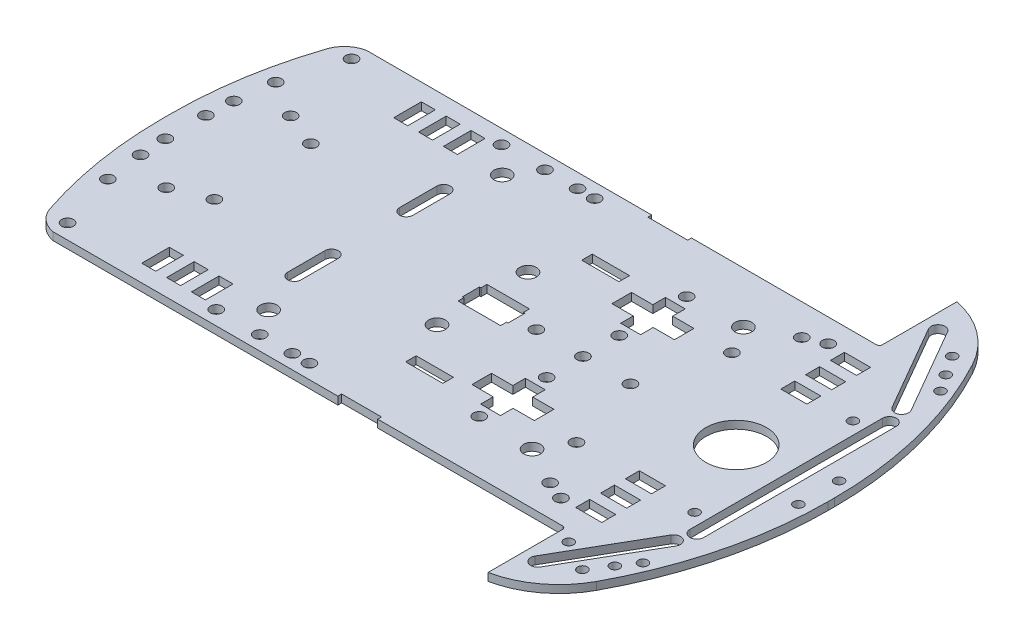
from build123d import *

# Parameters (mm, degrees)
BOSS_EXTRUDE1_DEPTH = 2.5
FILLET1_R           = 1
SKETCH2_W           = 12.85
SKETCH2_H           = 1.22
CUT_EXTRUDE1_DEPTH  = 2.5
SKETCH3_W           = 4.5
SKETCH3_H           = 8.9
CUT_EXTRUDE2_DEPTH  = 2.5
CUT_EXTRUDE3_DEPTH  = 2.5
SKETCH5_R           = 1.9
CUT_EXTRUDE4_DEPTH  = 2.5
SKETCH6_W           = 12
SKETCH6_H           = 3.4
CUT_EXTRUDE5_DEPTH  = 2.5
SKETCH7_W           = 8.4
SKETCH7_H           = 4.5
CUT_EXTRUDE6_DEPTH  = 2.5
SKETCH8_R           = 9.75
CUT_EXTRUDE7_DEPTH  = 2.5
SKETCH9_R           = 2.7
CUT_EXTRUDE8_DEPTH  = 2.5
SKETCH10_R          = 1.9
CUT_EXTRUDE9_DEPTH  = 2.5
SKETCH11_R          = 1.9
CUT_EXTRUDE10_DEPTH = 2.5
SKETCH12_R          = 1.9
CUT_EXTRUDE11_DEPTH = 2.5
SKETCH13_R          = 1.55
CUT_EXTRUDE12_DEPTH = 2.5
SKETCH14_R          = 1.55
CUT_EXTRUDE13_DEPTH = 2.5
SKETCH15_R          = 2.7
CUT_EXTRUDE14_DEPTH = 2.5
SKETCH16_R          = 1.9
CUT_EXTRUDE15_DEPTH = 2.5
SKETCH17_R          = 1.9
CUT_EXTRUDE16_DEPTH = 2.5
CUT_EXTRUDE17_DEPTH = 2.5
CUT_EXTRUDE18_DEPTH = 2.5
CUT_EXTRUDE19_DEPTH = 2.5
SKETCH21_R          = 1.55
CUT_EXTRUDE20_DEPTH = 2.5


with BuildPart() as part:
    # Sketch1 → Boss-Extrude1 (new body)
    with BuildSketch(Plane(origin=(0, 0, 0), x_dir=(1, 0, 0), z_dir=(0, 1, 0))):
        with BuildLine():
            Line((165, 101.05), (165, 126.05))
            ThreePointArc((165, 126.05), (176.651902275, 120.752536367), (185, 111.05))
            ThreePointArc((185, 111.05), (196.19228575, 82.2179374), (200, 51.525))
            Line((200, 51.525), (200, 49.525))
            ThreePointArc((200, 49.525), (196.19228575, 18.8320626), (185, -10))
            ThreePointArc((185, -10), (176.651902275, -19.702536367), (165, -25))
            Line((165, -25), (165, 0))
            Line((165, 0), (0, 0))
            ThreePointArc((0, 0), (-4.329635162, 2.032092311), (-7, 6))
            ThreePointArc((-7, 6), (-12.238570145, 27.229641406), (-14, 49.025))
            Line((-14, 49.025), (-14, 52.025))
            ThreePointArc((-14, 52.025), (-12.238570145, 73.820358594), (-7, 95.05))
            ThreePointArc((-7, 95.05), (-4.329635162, 99.017907689), (0, 101.05))
            Line((0, 101.05), (165, 101.05))
        make_face()
    extrude(amount=BOSS_EXTRUDE1_DEPTH)

    # Fillet1
    fillet1_edges = [part.edges().sort_by_distance(p)[0] for p in [
        (165, 1.25, -101.05),
        (165, 1.25, 0),
    ]]
    fillet(fillet1_edges, radius=FILLET1_R)

    # Sketch2 → Cut-Extrude1 (cut)
    with BuildSketch(Plane(origin=(0, 2.5, 0), x_dir=(1, 0, 0), z_dir=(0, 1, 0))):
        with Locations((98.075, 100.44)):
            Rectangle(SKETCH2_W, SKETCH2_H)
        with Locations((98.075, 0.61)):
            Rectangle(SKETCH2_W, SKETCH2_H)
    extrude(amount=-CUT_EXTRUDE1_DEPTH, mode=Mode.SUBTRACT)

    # Sketch3 → Cut-Extrude2 (cut)
    with BuildSketch(Plane(origin=(0, 2.5, 0), x_dir=(1, 0, 0), z_dir=(0, 1, 0))):
        with Locations((25.25, 91.1)):
            Rectangle(SKETCH3_W, SKETCH3_H)
        with Locations((33.25, 91.1)):
            Rectangle(SKETCH3_W, SKETCH3_H)
        with Locations((41.25, 91.1)):
            Rectangle(SKETCH3_W, SKETCH3_H)
        with Locations((41.25, 9.95)):
            Rectangle(SKETCH3_W, SKETCH3_H)
        with Locations((33.25, 9.95)):
            Rectangle(SKETCH3_W, SKETCH3_H)
        with Locations((25.25, 9.95)):
            Rectangle(SKETCH3_W, SKETCH3_H)
    extrude(amount=-CUT_EXTRUDE2_DEPTH, mode=Mode.SUBTRACT)

    # Sketch4 → Cut-Extrude3 (cut)
    with BuildSketch(Plane(origin=(0, 2.5, 0), x_dir=(1, 0, 0), z_dir=(0, 1, 0))):
        Polygon((84.48, 55.175), (84.48, 53.245), (84, 53.245), (84, 47.805), (84.48, 47.805), (84.48, 45.875), (98.18, 45.875), (98.18, 47.805), (98.66, 47.805), (98.66, 53.245), (98.18, 53.245), (98.18, 55.175), align=None)
    extrude(amount=-CUT_EXTRUDE3_DEPTH, mode=Mode.SUBTRACT)

    # Sketch5 → Cut-Extrude4 (cut)
    with BuildSketch(Plane(origin=(0, 2.5, 0), x_dir=(1, 0, 0), z_dir=(0, 1, 0))):
        with Locations((105.06, 50.525)):
            Circle(SKETCH5_R)
        with Locations((120.06, 50.525)):
            Circle(SKETCH5_R)
        with Locations((135.36, 50.525)):
            Circle(SKETCH5_R)
        with Locations((120.06, 62.225)):
            Circle(SKETCH5_R)
        with Locations((120.06, 83.925)):
            Circle(SKETCH5_R)
        with Locations((120.06, 17.125)):
            Circle(SKETCH5_R)
        with Locations((120.06, 38.825)):
            Circle(SKETCH5_R)
        Polygon((116.86, 65.875), (120.06, 65.875), (123.26, 65.875), (123.26, 69.925), (130.11, 69.925), (130.11, 76.225), (123.26, 76.225), (123.26, 80.275), (116.86, 80.275), (116.86, 76.225), (110.01, 76.225), (110.01, 69.925), (116.86, 69.925), align=None)
        Polygon((116.86, 31.125), (116.86, 35.175), (120.06, 35.175), (123.26, 35.175), (123.26, 31.125), (130.11, 31.125), (130.11, 24.825), (123.26, 24.825), (123.26, 20.775), (116.86, 20.775), (116.86, 24.825), (110.01, 24.825), (110.01, 31.125), align=None)
    extrude(amount=-CUT_EXTRUDE4_DEPTH, mode=Mode.SUBTRACT)

    # Sketch6 → Cut-Extrude5 (cut)
    with BuildSketch(Plane(origin=(0, 2.5, 0), x_dir=(1, 0, 0), z_dir=(0, 1, 0))):
        with Locations((99, 78.88)):
            Rectangle(SKETCH6_W, SKETCH6_H)
        with Locations((99, 22.17)):
            Rectangle(SKETCH6_W, SKETCH6_H)
    extrude(amount=-CUT_EXTRUDE5_DEPTH, mode=Mode.SUBTRACT)

    # Sketch7 → Cut-Extrude6 (cut)
    with BuildSketch(Plane(origin=(0, 2.5, 0), x_dir=(1, 0, 0), z_dir=(0, 1, 0))):
        with Locations((165.2, 91.55)):
            Rectangle(SKETCH7_W, SKETCH7_H)
        with Locations((165.2, 83.55)):
            Rectangle(SKETCH7_W, SKETCH7_H)
        with Locations((165.2, 75.55)):
            Rectangle(SKETCH7_W, SKETCH7_H)
        with Locations((165.2, 25.5)):
            Rectangle(SKETCH7_W, SKETCH7_H)
        with Locations((165.2, 17.5)):
            Rectangle(SKETCH7_W, SKETCH7_H)
        with Locations((165.2, 9.5)):
            Rectangle(SKETCH7_W, SKETCH7_H)
    extrude(amount=-CUT_EXTRUDE6_DEPTH, mode=Mode.SUBTRACT)

    # Sketch8 → Cut-Extrude7 (cut)
    with BuildSketch(Plane(origin=(0, 2.5, 0), x_dir=(1, 0, 0), z_dir=(0, 1, 0))):
        with Locations((169.41, 50.525)):
            Circle(SKETCH8_R)
    extrude(amount=-CUT_EXTRUDE7_DEPTH, mode=Mode.SUBTRACT)

    # Sketch9 → Cut-Extrude8 (cut)
    with BuildSketch(Plane(origin=(0, 2.5, 0), x_dir=(1, 0, 0), z_dir=(0, 1, 0))):
        with Locations((87.7, 65.175)):
            Circle(SKETCH9_R)
        with Locations((87.7, 35.875)):
            Circle(SKETCH9_R)
        with Locations((56.45, 88.15)):
            Circle(SKETCH9_R)
        with Locations((56.45, 12.9)):
            Circle(SKETCH9_R)
    extrude(amount=-CUT_EXTRUDE8_DEPTH, mode=Mode.SUBTRACT)

    # Sketch10 → Cut-Extrude9 (cut)
    with BuildSketch(Plane(origin=(0, 2.5, 0), x_dir=(1, 0, 0), z_dir=(0, 1, 0))):
        with Locations((47.9, 96.45)):
            Circle(SKETCH10_R)
        with Locations((61.9, 96.45)):
            Circle(SKETCH10_R)
        with Locations((72.4, 96.45)):
            Circle(SKETCH10_R)
        with Locations((77.9, 96.45)):
            Circle(SKETCH10_R)
        with Locations((77.9, 4.6)):
            Circle(SKETCH10_R)
        with Locations((72.4, 4.6)):
            Circle(SKETCH10_R)
        with Locations((61.9, 4.6)):
            Circle(SKETCH10_R)
        with Locations((47.9, 4.6)):
            Circle(SKETCH10_R)
    extrude(amount=-CUT_EXTRUDE9_DEPTH, mode=Mode.SUBTRACT)

    # Sketch11 → Cut-Extrude10 (cut)
    with BuildSketch(Plane(origin=(0, 2.5, 0), x_dir=(1, 0, 0), z_dir=(0, 1, 0))):
        with Locations((-0.2, 96.25)):
            Circle(SKETCH11_R)
        with Locations((-0.2, 4.8)):
            Circle(SKETCH11_R)
        with Locations((-5.9, 77.55)):
            Circle(SKETCH11_R)
        with Locations((-7.4, 65.55)):
            Circle(SKETCH11_R)
        with Locations((-7.9, 57.05)):
            Circle(SKETCH11_R)
        with Locations((-7.9, 44)):
            Circle(SKETCH11_R)
        with Locations((-7.4, 35.5)):
            Circle(SKETCH11_R)
        with Locations((-5.9, 23.5)):
            Circle(SKETCH11_R)
    extrude(amount=-CUT_EXTRUDE10_DEPTH, mode=Mode.SUBTRACT)

    # Sketch12 → Cut-Extrude11 (cut)
    with BuildSketch(Plane(origin=(0, 2.5, 0), x_dir=(1, 0, 0), z_dir=(0, 1, 0))):
        with Locations((5.9, 70.55)):
            Circle(SKETCH12_R)
        with Locations((16.9, 66.05)):
            Circle(SKETCH12_R)
        with Locations((5.9, 30.5)):
            Circle(SKETCH12_R)
        with Locations((16.9, 35)):
            Circle(SKETCH12_R)
    extrude(amount=-CUT_EXTRUDE11_DEPTH, mode=Mode.SUBTRACT)

    # Sketch13 → Cut-Extrude12 (cut)
    with BuildSketch(Plane(origin=(0, 2.5, 0), x_dir=(1, 0, 0), z_dir=(0, 1, 0))):
        with Locations((196, 57.075)):
            Circle(SKETCH13_R)
        with Locations((196, 43.975)):
            Circle(SKETCH13_R)
        with Locations((181.5, 25.025)):
            Circle(SKETCH13_R)
        with Locations((181.5, 76.025)):
            Circle(SKETCH13_R)
    extrude(amount=-CUT_EXTRUDE12_DEPTH, mode=Mode.SUBTRACT)

    # Sketch14 → Cut-Extrude13 (cut)
    with BuildSketch(Plane(origin=(0, 2.5, 0), x_dir=(1, 0, 0), z_dir=(0, 1, 0))):
        with Locations((169.5, -3.5)):
            Circle(SKETCH14_R)
    extrude(amount=-CUT_EXTRUDE13_DEPTH, mode=Mode.SUBTRACT)

    # Sketch15 → Cut-Extrude14 (cut)
    with BuildSketch(Plane(origin=(0, 2.5, 0), x_dir=(1, 0, 0), z_dir=(0, 1, 0))):
        with Locations((137.7, 16.5)):
            Circle(SKETCH15_R)
        with Locations((137.7, 84.55)):
            Circle(SKETCH15_R)
    extrude(amount=-CUT_EXTRUDE14_DEPTH, mode=Mode.SUBTRACT)

    # Sketch16 → Cut-Extrude15 (cut)
    with BuildSketch(Plane(origin=(0, 2.5, 0), x_dir=(1, 0, 0), z_dir=(0, 1, 0))):
        with Locations((143, 25.5)):
            Circle(SKETCH16_R)
        with Locations((143, 75.55)):
            Circle(SKETCH16_R)
    extrude(amount=-CUT_EXTRUDE15_DEPTH, mode=Mode.SUBTRACT)

    # Sketch17 → Cut-Extrude16 (cut)
    with BuildSketch(Plane(origin=(0, 2.5, 0), x_dir=(1, 0, 0), z_dir=(0, 1, 0))):
        with Locations((150, 10)):
            Circle(SKETCH17_R)
        with Locations((156, 7.5)):
            Circle(SKETCH17_R)
        with Locations((150, 91.05)):
            Circle(SKETCH17_R)
        with Locations((156, 93.55)):
            Circle(SKETCH17_R)
    extrude(amount=-CUT_EXTRUDE16_DEPTH, mode=Mode.SUBTRACT)

    # Sketch18 → Cut-Extrude17 (cut)
    with BuildSketch(Plane(origin=(0, 2.5, 0), x_dir=(1, 0, 0), z_dir=(0, 1, 0))):
        with BuildLine():
            Line((49, 74.55), (49, 62.55))
            ThreePointArc((49, 62.55), (51.15, 60.4), (53.3, 62.55))
            Line((53.3, 62.55), (53.3, 74.55))
            ThreePointArc((53.3, 74.55), (51.15, 76.7), (49, 74.55))
        make_face()
        with BuildLine():
            Line((53.3, 26.5), (53.3, 38.5))
            ThreePointArc((53.3, 38.5), (51.15, 40.65), (49, 38.5))
            Line((49, 38.5), (49, 26.5))
            ThreePointArc((49, 26.5), (51.15, 24.35), (53.3, 26.5))
        make_face()
    extrude(amount=-CUT_EXTRUDE17_DEPTH, mode=Mode.SUBTRACT)

    # Sketch19 → Cut-Extrude18 (cut)
    with BuildSketch(Plane(origin=(0, 2.5, 0), x_dir=(1, 0, 0), z_dir=(0, 1, 0))):
        with BuildLine():
            Line((190, 19.525), (190, 81.525))
            ThreePointArc((190, 81.525), (187.75, 83.775), (185.5, 81.525))
            Line((185.5, 81.525), (185.5, 19.525))
            ThreePointArc((185.5, 19.525), (187.75, 17.275), (190, 19.525))
        make_face()
    extrude(amount=-CUT_EXTRUDE18_DEPTH, mode=Mode.SUBTRACT)

    # Sketch20 → Cut-Extrude19 (cut)
    with BuildSketch(Plane(origin=(0, 2.5, 0), x_dir=(1, 0, 0), z_dir=(0, 1, 0))):
        with BuildLine():
            Line((168, -12.803847577), (184, 14.908965344))
            ThreePointArc((184, 14.908965344), (187.073557159, 15.732522502), (187.897114317, 12.658965344))
            Line((187.897114317, 12.658965344), (171.897114317, -15.053847577))
            ThreePointArc((171.897114317, -15.053847577), (168.823557159, -15.877404736), (168, -12.803847577))
        make_face()
        with BuildLine():
            Line((168, 113.853847577), (184, 86.141034656))
            ThreePointArc((184, 86.141034656), (187.073557159, 85.317477498), (187.897114317, 88.391034656))
            Line((187.897114317, 88.391034656), (171.897114317, 116.103847577))
            ThreePointArc((171.897114317, 116.103847577), (168.823557159, 116.927404736), (168, 113.853847577))
        make_face()
    extrude(amount=-CUT_EXTRUDE19_DEPTH, mode=Mode.SUBTRACT)

    # Sketch21 → Cut-Extrude20 (cut)
    with BuildSketch(Plane(origin=(0, 2.5, 0), x_dir=(1, 0, 0), z_dir=(0, 1, 0))):
        with Locations((187.294228634, 2.61473671)):
            Circle(SKETCH21_R)
        with Locations((179.42820323, -9.009618943)):
            Circle(SKETCH21_R)
        with Locations((183.611215932, -2.764428415)):
            Circle(SKETCH21_R)
        with Locations((179.42820323, 110.059618943)):
            Circle(SKETCH21_R)
        with Locations((183.611215932, 103.814428415)):
            Circle(SKETCH21_R)
        with Locations((187.294228634, 98.43526329)):
            Circle(SKETCH21_R)
    extrude(amount=-CUT_EXTRUDE20_DEPTH, mode=Mode.SUBTRACT)


solid = part.part
